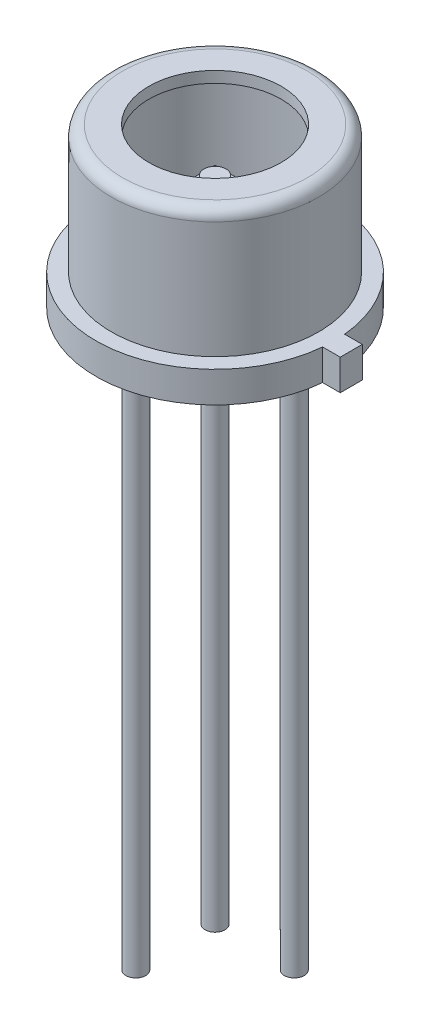
from build123d import *

# Parameters (mm, degrees)
SKETCH2_R           = 2.7
BOSS_EXTRUDE1_DEPTH = 0.446
BOSS_EXTRUDE2_START = -2.5
SKETCH3_W           = 0.6
SKETCH3_H           = 0.6
BOSS_EXTRUDE2_DEPTH = 0.05
SKETCH8_R           = 0.25
BOSS_EXTRUDE6_DEPTH = 0.1
BOSS_EXTRUDE8_DEPTH = 0.7
SKETCH5_R           = 0.225
BOSS_EXTRUDE4_DEPTH = 13


with BuildPart() as part:
    # Sketch1 → Revolve-Thin2 (revolve)
    with BuildSketch(Plane.XY, mode=Mode.PRIVATE) as revolve_thin2_sk:
        with BuildLine():
            Line((2.7, 0), (2.7, 0.7))
            Line((2.7, 0.7), (2.35, 0.7))
            Line((2.35, 0.7), (2.35, 3.346))
            ThreePointArc((2.35, 3.346), (2.275605122, 3.525605122), (2.096, 3.6))
            Line((2.096, 3.6), (1.5, 3.6))
            Line((1.5, 3.6), (1.5, 3.346))
            Line((1.5, 3.346), (2.096, 3.346))
            Line((2.096, 3.346), (2.096, 0.446))
            Line((2.096, 0.446), (2.446, 0.446))
            Line((2.446, 0.446), (2.446, 0))
            Line((2.446, 0), (2.7, 0))
        make_face()
    revolve(revolve_thin2_sk.sketch.rotate(Axis((0, 0, 0), (0, 1, 0)), 90), axis=Axis((0, 0, 0), (0, 1, 0)))  # turned: the seam where the file's is

    # Sketch2 → Boss-Extrude1 (add)
    with BuildSketch(Plane.XZ):
        with Locations(Location((0, 0, 0), (0, 0, 270))):  # turned: the seam where the file's is
            Circle(SKETCH2_R)
    extrude(amount=-BOSS_EXTRUDE1_DEPTH)

    # Sketch11 → Boss-Extrude8 (add)
    with BuildSketch(Plane.XZ):
        with BuildLine():
            Line((3.088401012, -0.25), (3.088401012, 0))
            Line((3.088401012, 0), (3.088401012, 0.25))
            Line((3.088401012, 0.25), (2.688401012, 0.25))
            ThreePointArc((2.688401012, 0.25), (2.697098694, 0.125134464), (2.7, 0))
            ThreePointArc((2.7, 0), (2.697098694, -0.125134464), (2.688401012, -0.25))
            Line((2.688401012, -0.25), (3.088401012, -0.25))
        make_face()
    extrude(amount=-BOSS_EXTRUDE8_DEPTH)

    # Sketch5 → Boss-Extrude4 (add)
    with BuildSketch(Plane.XZ):
        with Locations(Location((0.898025612, -0.898025612, 0), (0, 0, 90))):  # turned: the seam where the file's is
            Circle(SKETCH5_R)
        with Locations(Location((-0.898025612, 0.898025612, 0), (0, 0, 90))):  # turned: the seam where the file's is
            Circle(SKETCH5_R)
        with Locations(Location((-0.898025612, -0.898025612, 0), (0, 0, 90))):  # turned: the seam where the file's is
            Circle(SKETCH5_R)
    extrude(amount=BOSS_EXTRUDE4_DEPTH)


with BuildPart() as body_2:
    # Sketch3 → Boss-Extrude2 (new body)
    with BuildSketch(Plane.XZ.offset(BOSS_EXTRUDE2_START)):
        Rectangle(SKETCH3_W, SKETCH3_H)
    extrude(amount=BOSS_EXTRUDE2_DEPTH)

    # Sketch8 → Boss-Extrude6 (add)
    with BuildSketch(Plane(origin=(0, 2.5, 0), x_dir=(-1, 0, 0), z_dir=(0, 1, 0))):
        with Locations(Location((0, 0, 0), (0, 0, 270))):  # turned: the seam where the file's is
            Circle(SKETCH8_R)
    extrude(amount=BOSS_EXTRUDE6_DEPTH)


solid = Compound([part.part, body_2.part])
